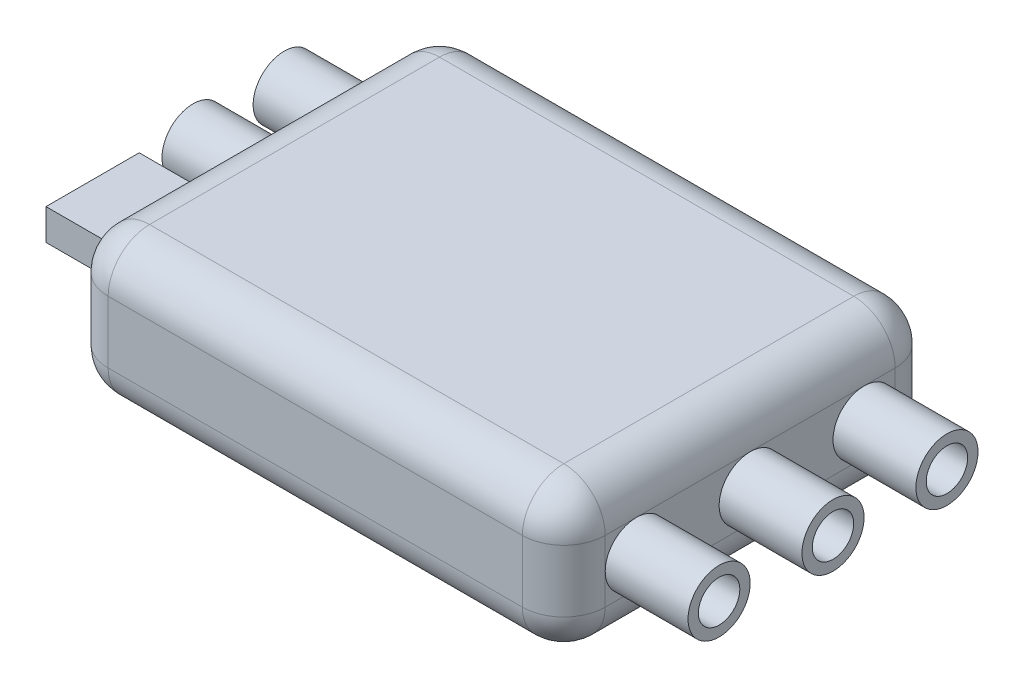
from build123d import *

# Parameters (mm, degrees)
SKETCH1_W           = 24
SKETCH1_H           = 18
BOSS_EXTRUDE1_DEPTH = 7
FILLET2_R           = 2
SKETCH2_R           = 1.5
SKETCH2_R_2         = 1
BOSS_EXTRUDE2_DEPTH = 4
SKETCH3_R           = 1.5
SKETCH3_R_2         = 1
SKETCH3_W           = 4.5
SKETCH3_H           = 1.5
BOSS_EXTRUDE3_DEPTH = 4


with BuildPart() as part:
    # Sketch1 → Boss-Extrude1 (new body)
    with BuildSketch(Plane(origin=(0, 0, 0), x_dir=(1, 0, 0), z_dir=(0, 1, 0))):
        Rectangle(SKETCH1_W, SKETCH1_H)
    extrude(amount=BOSS_EXTRUDE1_DEPTH)

    # Fillet2
    fillet2_edges = [part.edges().sort_by_distance(p)[0] for p in [
        (-12, 7, 0),
        (0, 7, 9),
        (12, 7, 0),
        (0, 0, 9),
        (-12, 0, 0),
        (0, 0, -9),
        (12, 0, 0),
        (12, 3.5, 9),
        (-12, 3.5, 9),
        (-12, 3.5, -9),
        (12, 3.5, -9),
        (0, 7, -9),
    ]]
    fillet(fillet2_edges, radius=FILLET2_R)

    # Sketch2 → Boss-Extrude2 (add)
    with BuildSketch(Plane(origin=(12, 0, 0), x_dir=(0, 0, -1), z_dir=(1, 0, 0))):
        with Locations((-5.5, 3.5)):
            Circle(SKETCH2_R)
        with Locations((-5.5, 3.5)):
            Circle(SKETCH2_R_2, mode=Mode.SUBTRACT)
        with Locations((0, 3.5)):
            Circle(SKETCH2_R)
        with Locations((0, 3.5)):
            Circle(SKETCH2_R_2, mode=Mode.SUBTRACT)
        with Locations((5.5, 3.5)):
            Circle(SKETCH2_R)
        with Locations((5.5, 3.5)):
            Circle(SKETCH2_R_2, mode=Mode.SUBTRACT)
    extrude(amount=BOSS_EXTRUDE2_DEPTH)

    # Sketch3 → Boss-Extrude3 (add)
    with BuildSketch(Plane.ZY.offset(12)):
        with Locations((-5.5, 3.5)):
            Circle(SKETCH3_R)
        with Locations((-5.5, 3.5)):
            Circle(SKETCH3_R_2, mode=Mode.SUBTRACT)
        with Locations((-1.1, 3.5)):
            Circle(SKETCH3_R)
        with Locations((-1.1, 3.5)):
            Circle(SKETCH3_R_2, mode=Mode.SUBTRACT)
        with Locations((3.75, 3.5)):
            Rectangle(SKETCH3_W, SKETCH3_H)
    extrude(amount=BOSS_EXTRUDE3_DEPTH)


solid = part.part
